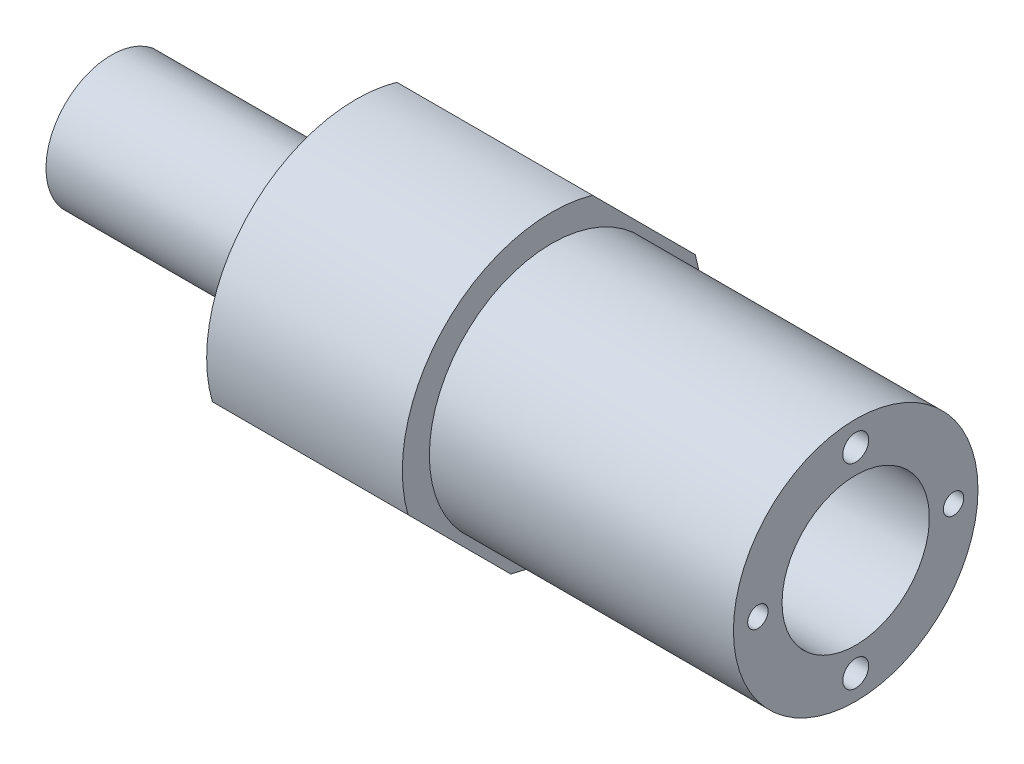
from build123d import *

# Parameters (mm, degrees)
CUT_EXTRUDE1_REACH          = 93.3
SKETCH8_R                   = 1.5875
TAP_DRILL_FOR_M3_TAP2_D     = 2.5
TAP_DRILL_FOR_M3_TAP2_DEPTH = 6
TAP_DRILL_FOR_M3_TAP2_TIP   = 0.751075774
TAP_DRILL_FOR_M4_TAP1_D     = 3.3
TAP_DRILL_FOR_M4_TAP1_DEPTH = 10
TAP_DRILL_FOR_M4_TAP1_TIP   = 0.991420021
CUT_EXTRUDE2_DEPTH          = 30
CIRPATTERN1_COUNT           = 2
CUT_EXTRUDE3_REACH          = 42.6
SKETCH19_R                  = 0.8


with BuildPart() as part:
    # Sketch3 → Revolve1 (revolve)
    with BuildSketch(Plane.XY):
        Polygon((208.579017697, -139.537446021), (250.685153788, -139.537446021), (259.278559985, -139.537446021), (259.278559985, -133.573704322), (238.427343436, -133.573704322), (221.978559985, -133.573704322), (221.978559985, -130.256968654), (197.978559985, -130.256968654), (197.978559985, -140.547506676), (167.978559985, -140.547506676), (167.978559985, -145.190124478), (205.151545348, -145.190124478), (205.151545348, -140.547506676), (208.579017697, -140.547506676), align=None)
    revolve(axis=Axis((227.370475166, -148.573704322, 0), (1, 0, 0)))

    # Sketch8 → Cut-Extrude1 (cut, up to next)
    with BuildSketch(Plane(origin=(259.278559985, 0, 0), x_dir=(0, 0, -1), z_dir=(1, 0, 0)), mode=Mode.PRIVATE) as cut_extrude1_sk1:
        with Locations((0, -136.573704322)):
            Circle(SKETCH8_R)
    cut_extrude1_tool1 = extrude(cut_extrude1_sk1.sketch, amount=-CUT_EXTRUDE1_REACH, mode=Mode.PRIVATE) & part.part
    add(cut_extrude1_tool1.solids().sort_by_distance((259.27856, -136.573704, 0))[0], mode=Mode.SUBTRACT)
    # Sketch8 → Cut-Extrude1 (cut, up to next)
    with BuildSketch(Plane(origin=(259.278559985, 0, 0), x_dir=(0, 0, -1), z_dir=(1, 0, 0)), mode=Mode.PRIVATE) as cut_extrude1_sk2:
        with Locations((0, -160.573704322)):
            Circle(SKETCH8_R)
    cut_extrude1_tool2 = extrude(cut_extrude1_sk2.sketch, amount=-CUT_EXTRUDE1_REACH, mode=Mode.PRIVATE) & part.part
    add(cut_extrude1_tool2.solids().sort_by_distance((259.27856, -160.573704, 0))[0], mode=Mode.SUBTRACT)

    # Tap Drill for M3 Tap2
    with Locations(Plane(origin=(259.278559985, 0, 0), x_dir=(0, 0, -1), z_dir=(1, 0, 0))):
        with Locations((-12, -148.573704322), (12, -148.573704322)):
            Hole(TAP_DRILL_FOR_M3_TAP2_D / 2, depth=TAP_DRILL_FOR_M3_TAP2_DEPTH)
            with Locations((0, 0, -(TAP_DRILL_FOR_M3_TAP2_DEPTH + TAP_DRILL_FOR_M3_TAP2_TIP / 2))):  # 118° drill point
                Cone(0, TAP_DRILL_FOR_M3_TAP2_D / 2, TAP_DRILL_FOR_M3_TAP2_TIP, mode=Mode.SUBTRACT)

    # Tap Drill for M4 Tap1
    with Locations(Plane.ZY.offset(-197.978559985)):
        with Locations((-12, -148.573704322), (12, -148.573704322)):
            Hole(TAP_DRILL_FOR_M4_TAP1_D / 2, depth=TAP_DRILL_FOR_M4_TAP1_DEPTH)
            with Locations((0, 0, -(TAP_DRILL_FOR_M4_TAP1_DEPTH + TAP_DRILL_FOR_M4_TAP1_TIP / 2))):  # 118° drill point
                Cone(0, TAP_DRILL_FOR_M4_TAP1_D / 2, TAP_DRILL_FOR_M4_TAP1_TIP, mode=Mode.SUBTRACT)

    # Sketch16 → Cut-Extrude2 (cut)
    with BuildSketch(Plane.ZY.offset(-197.978559985)):
        Polygon((-1.637133312, -127.583420636), (-21.615778458, -147.562065782), (-21.615778458, -136.774049127), align=None)
        Polygon((24.069809273, -155.63537923), (24.069809273, -147.131312047), (1.983531933, -169.217589388), align=None)
    extrude(amount=-CUT_EXTRUDE2_DEPTH, mode=Mode.SUBTRACT)

    # Sketch18 → Tap Drill for M5 Tap1 (revolve, cut)
    with BuildSketch(Plane(origin=(209.978559985, -137.259995823, -11.313708499), x_dir=(0, 0.707106781, 0.707106781), z_dir=(1, 0, 0))):
        Polygon((0, 0), (0, 5.2618073), (2.1, 4), (2.1, 0), align=None)
    tap_drill_for_m5_tap1 = revolve(axis=Axis((209.978559985, -132.769867763, -15.80383656), (0, -0.707106781, 0.707106781)), mode=Mode.SUBTRACT)

    # CirPattern1: Tap Drill for M5 Tap1 ×2 about axis
    cirpattern1_axis = Axis((205.151545348, -148.573704322, 0), (-1, 0, 0))
    for i in range(1, CIRPATTERN1_COUNT):
        add(tap_drill_for_m5_tap1.rotate(cirpattern1_axis, i * 360 / CIRPATTERN1_COUNT), mode=Mode.SUBTRACT)

    # Sketch19 → Cut-Extrude3 (cut, up to next)
    with BuildSketch(Plane(origin=(208.579017697, 0, 0), x_dir=(0, 0, -1), z_dir=(1, 0, 0)), mode=Mode.PRIVATE) as cut_extrude3_sk1:
        with Locations((5.586143571, -142.987560751)):
            Circle(SKETCH19_R)
    cut_extrude3_tool1 = extrude(cut_extrude3_sk1.sketch, amount=-CUT_EXTRUDE3_REACH, mode=Mode.PRIVATE) & part.part
    add(cut_extrude3_tool1.solids().sort_by_distance((208.579018, -142.987561, -5.586144))[0], mode=Mode.SUBTRACT)


solid = part.part
